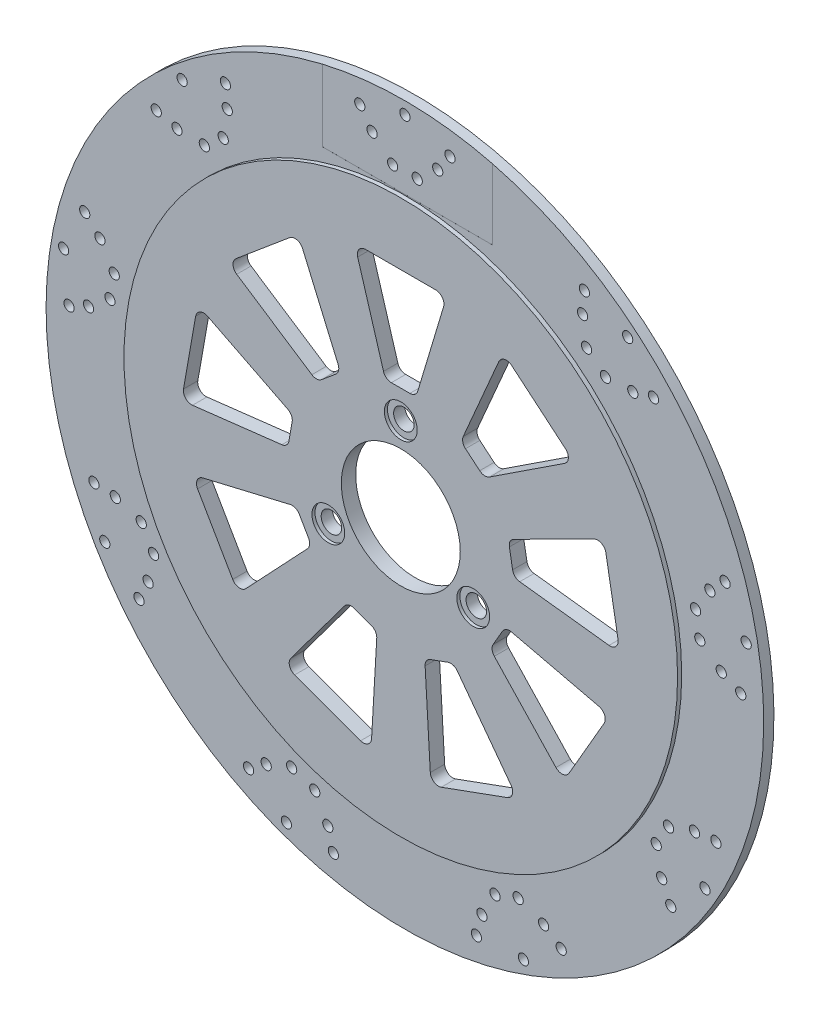
from build123d import *

# Parameters (mm, degrees)
SKETCH1_R           = 175
SKETCH1_R_2         = 29
BOSS_EXTRUDE1_DEPTH = 7
SKETCH2_R           = 175
SKETCH2_R_2         = 135
CUT_EXTRUDE1_DEPTH  = 2
SKETCH3_R           = 5
CUT_EXTRUDE2_DEPTH  = 8
CIRPATTERN1_COUNT   = 3
SKETCH4_R           = 8
CUT_EXTRUDE3_DEPTH  = 1.5
CIRPATTERN2_COUNT   = 3
CUT_EXTRUDE4_DEPTH  = 8
CIRPATTERN3_COUNT   = 9
SKETCH7_R           = 2.5
CUT_EXTRUDE5_DEPTH  = 8
CIRPATTERN4_COUNT   = 9
SKETCH8_R           = 175
SKETCH8_R_2         = 135
CUT_EXTRUDE6_DEPTH  = 0.01
SKETCH13_W          = 79.292042598
SKETCH13_H          = 39.876075581
CUT_EXTRUDE16_DEPTH = 0.01
SKETCH14_W          = 82.870153534
SKETCH14_H          = 46.717889934
CUT_EXTRUDE17_DEPTH = 0.01


with BuildPart() as part:
    # Sketch1 → Boss-Extrude1 (new body)
    with BuildSketch(Plane.XY):
        Circle(SKETCH1_R)
        Circle(SKETCH1_R_2, mode=Mode.SUBTRACT)
    extrude(amount=BOSS_EXTRUDE1_DEPTH)

    # Sketch2 → Cut-Extrude1 (cut)
    with BuildSketch(Plane.XY.offset(7)):
        Circle(SKETCH2_R)
        Circle(SKETCH2_R_2, mode=Mode.SUBTRACT)
    extrude(amount=-CUT_EXTRUDE1_DEPTH, mode=Mode.SUBTRACT)

    # Sketch3 → Cut-Extrude2 (cut, through all)
    with BuildSketch(Plane.XY.offset(7)):
        with Locations((0, 40.8)):
            Circle(SKETCH3_R)
    cut_extrude2 = extrude(amount=-CUT_EXTRUDE2_DEPTH, mode=Mode.SUBTRACT)

    # CirPattern1: Cut-Extrude2 ×3 about axis
    cirpattern1_axis = Axis((0, 0, 0), (0, 0, 1))
    for i in range(1, CIRPATTERN1_COUNT):
        add(cut_extrude2.rotate(cirpattern1_axis, i * 360 / CIRPATTERN1_COUNT), mode=Mode.SUBTRACT)

    # Sketch4 → Cut-Extrude3 (cut)
    with BuildSketch(Plane.XY.offset(7)):
        with Locations((0, 40.8)):
            Circle(SKETCH4_R)
    cut_extrude3 = extrude(amount=-CUT_EXTRUDE3_DEPTH, mode=Mode.SUBTRACT)

    # CirPattern2: Cut-Extrude3 ×3 about axis
    cirpattern2_axis = Axis((0, 0, 0), (0, 0, 1))
    for i in range(1, CIRPATTERN2_COUNT):
        add(cut_extrude3.rotate(cirpattern2_axis, i * 360 / CIRPATTERN2_COUNT), mode=Mode.SUBTRACT)

    # Sketch5 → Cut-Extrude4 (cut, through all)
    with BuildSketch(Plane.XY.offset(7)):
        with BuildLine():
            Line((-4.596961597, 54.583584838), (4.450793196, 54.583584838))
            ThreePointArc((4.450793196, 54.583584838), (6.838515315, 55.374413125), (8.282098337, 57.434193296))
            Line((8.282098337, 57.434193296), (20.882098337, 99.434193296))
            ThreePointArc((20.882098337, 99.434193296), (20.259964909, 102.971306957), (17.050793196, 104.583584838))
            Line((17.050793196, 104.583584838), (-17.196961597, 104.583584838))
            ThreePointArc((-17.196961597, 104.583584838), (-20.40613331, 102.971306957), (-21.028266737, 99.434193296))
            Line((-21.028266737, 99.434193296), (-8.428266737, 57.434193296))
            ThreePointArc((-8.428266737, 57.434193296), (-6.984683715, 55.374413125), (-4.596961597, 54.583584838))
        make_face()
    cut_extrude4 = extrude(amount=-CUT_EXTRUDE4_DEPTH, mode=Mode.SUBTRACT)

    # CirPattern3: Cut-Extrude4 ×9 about axis
    cirpattern3_axis = Axis((0, 0, 0), (0, 0, 1))
    for i in range(1, CIRPATTERN3_COUNT):
        add(cut_extrude4.rotate(cirpattern3_axis, i * 360 / CIRPATTERN3_COUNT), mode=Mode.SUBTRACT)

    # Sketch7 → Cut-Extrude5 (cut, through all)
    with BuildSketch(Plane.XY.offset(7)):
        with Locations((-16, 153.847810574)):
            Circle(SKETCH7_R)
        with Locations((0, 169.006064036)):
            Circle(SKETCH7_R)
        with Locations((-6, 145.006064036)):
            Circle(SKETCH7_R)
        with Locations((6, 145.006064036)):
            Circle(SKETCH7_R)
        with Locations((16, 153.847810574)):
            Circle(SKETCH7_R)
        with Locations((-22, 162.429292467)):
            Circle(SKETCH7_R)
        with Locations((22, 162.429292467)):
            Circle(SKETCH7_R)
    cut_extrude5 = extrude(amount=-CUT_EXTRUDE5_DEPTH, mode=Mode.SUBTRACT)

    # CirPattern4: Cut-Extrude5 ×9 about axis
    cirpattern4_axis = Axis((0, 0, 0), (0, 0, 1))
    for i in range(1, CIRPATTERN4_COUNT):
        add(cut_extrude5.rotate(cirpattern4_axis, i * 360 / CIRPATTERN4_COUNT), mode=Mode.SUBTRACT)

    # Sketch8 → Cut-Extrude6 (cut)
    with BuildSketch(Plane.XY):
        Circle(SKETCH8_R)
        Circle(SKETCH8_R_2, mode=Mode.SUBTRACT)
    extrude(amount=CUT_EXTRUDE6_DEPTH, mode=Mode.SUBTRACT)

    # Sketch13 → Cut-Extrude16 (cut)
    with BuildSketch(Plane(origin=(0, 0, 0.01), x_dir=(-1, 0, 0), z_dir=(0, 0, -1))):
        with Locations((1.151688722, 155.572141176)):
            Rectangle(SKETCH13_W, SKETCH13_H)
    extrude(amount=-CUT_EXTRUDE16_DEPTH, mode=Mode.SUBTRACT)

    # Sketch14 → Cut-Extrude17 (cut)
    with BuildSketch(Plane.XY.offset(5)):
        with Locations((1.260816627, 158.757260012)):
            Rectangle(SKETCH14_W, SKETCH14_H)
    extrude(amount=-CUT_EXTRUDE17_DEPTH, mode=Mode.SUBTRACT)


solid = part.part
